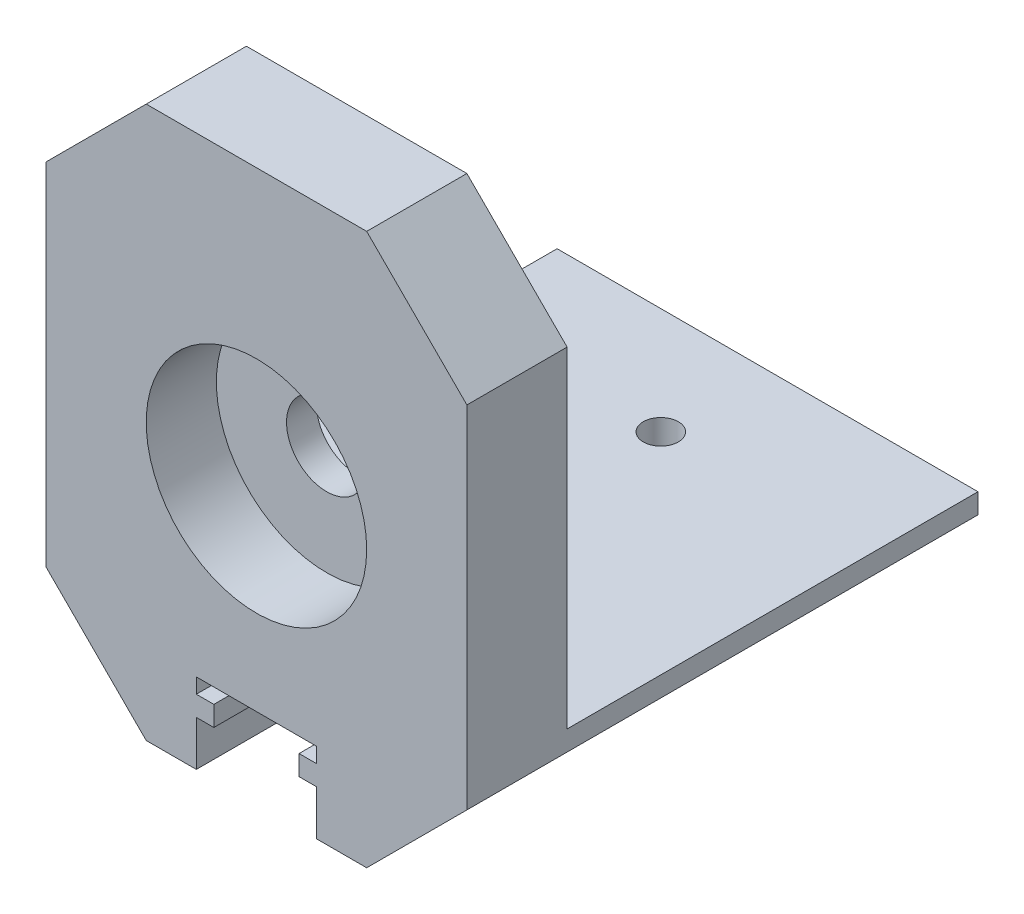
from build123d import *

# Parameters (mm, degrees)
ESTRUSIONE_ESTRUSIONE1_DEPTH = 10
SCHIZZO2_R                   = 11
TAGLIO_ESTRUSIONE1_DEPTH     = 7
SCHIZZO3_R                   = 4
TAGLIO_ESTRUSIONE2_DEPTH     = 4
ESTRUSIONE_ESTRUSIONE2_DEPTH = 41
SMUSSO1_SIZE                 = 10
SCHIZZO5_R                   = 1.75
TAGLIO_ESTRUSIONE3_DEPTH     = 13


with BuildPart() as part:
    # Schizzo1 → Estrusione-Estrusione1 (new body)
    with BuildSketch(Plane.XY):
        Polygon((6, -23), (6, -27.5), (21, -27.5), (21, 27.5), (-21, 27.5), (-21, -27.5), (-6, -27.5), (-6, -23), (-4.25, -23), (-4.25, -21), (-6, -21), (-6, -19.5), (6, -19.5), (6, -21), (4.25, -21), (4.25, -23), align=None)
    extrude(amount=ESTRUSIONE_ESTRUSIONE1_DEPTH)

    # Schizzo2 → Taglio-Estrusione1 (cut)
    with BuildSketch(Plane.XY.offset(10)):
        Circle(SCHIZZO2_R)
    extrude(amount=-TAGLIO_ESTRUSIONE1_DEPTH, mode=Mode.SUBTRACT)

    # Schizzo3 → Taglio-Estrusione2 (cut, through all)
    with BuildSketch(Plane.XY.offset(3)):
        Circle(SCHIZZO3_R)
    extrude(amount=-TAGLIO_ESTRUSIONE2_DEPTH, mode=Mode.SUBTRACT)

    # Schizzo4 → Estrusione-Estrusione2 (add)
    with BuildSketch(Plane(origin=(0, 0, 0), x_dir=(-1, 0, 0), z_dir=(0, 0, -1))):
        Polygon((-21, -27.5), (-6, -27.5), (-6, -23), (-4.25, -23), (-4.25, -21), (-6, -21), (-6, -19.5), (6, -19.5), (6, -21), (4.25, -21), (4.25, -23), (6, -23), (6, -27.5), (21, -27.5), (21, -15.5), (-21, -15.5), align=None)
    extrude(amount=ESTRUSIONE_ESTRUSIONE2_DEPTH)

    # Smusso1
    smusso1_edges = [part.edges().sort_by_distance(p)[0] for p in [
        (21, -27.5, -15.5),
        (-21, -27.5, -15.5),
        (-21, 27.5, 5),
        (21, 27.5, 5),
    ]]
    chamfer(smusso1_edges, length=SMUSSO1_SIZE)

    # Schizzo5 → Taglio-Estrusione3 (cut, through all)
    with BuildSketch(Plane(origin=(0, -15.5, 0), x_dir=(1, 0, 0), z_dir=(0, 1, 0))):
        with Locations((0, 30.35)):
            Circle(SCHIZZO5_R)
        with Locations((0, 5.35)):
            Circle(SCHIZZO5_R)
    extrude(amount=-TAGLIO_ESTRUSIONE3_DEPTH, mode=Mode.SUBTRACT)


solid = part.part
